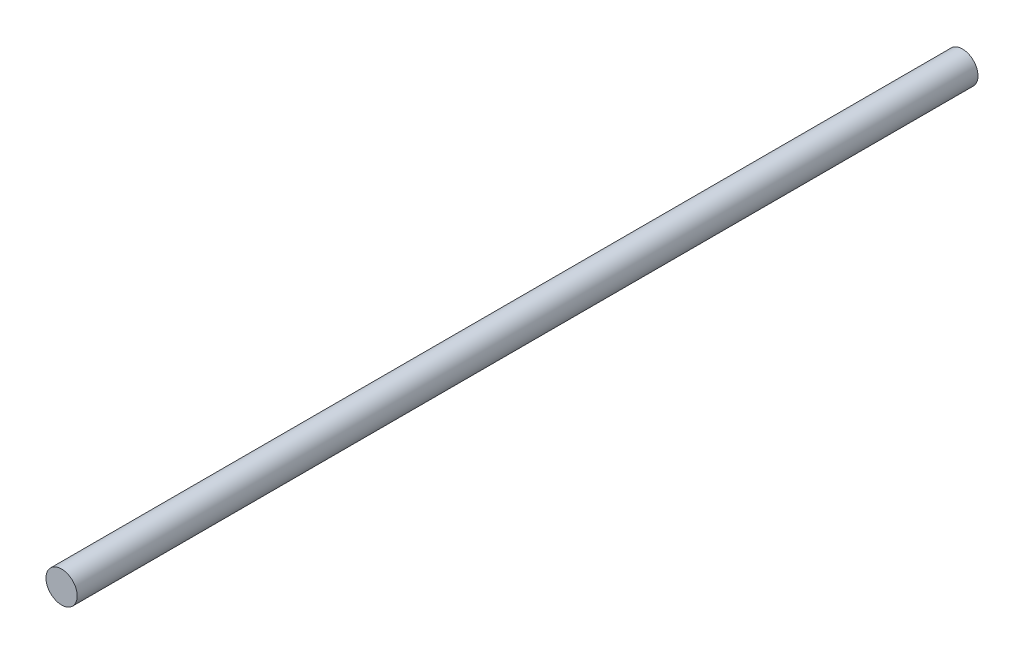
from build123d import *

# Parameters (mm, degrees)
SKETCH1_R           = 5
BOSS_EXTRUDE1_DEPTH = 288.5


with BuildPart() as part:
    # Sketch1 → Boss-Extrude1 (new body)
    with BuildSketch(Plane.XY):
        Circle(SKETCH1_R)
    extrude(amount=BOSS_EXTRUDE1_DEPTH)


solid = part.part
